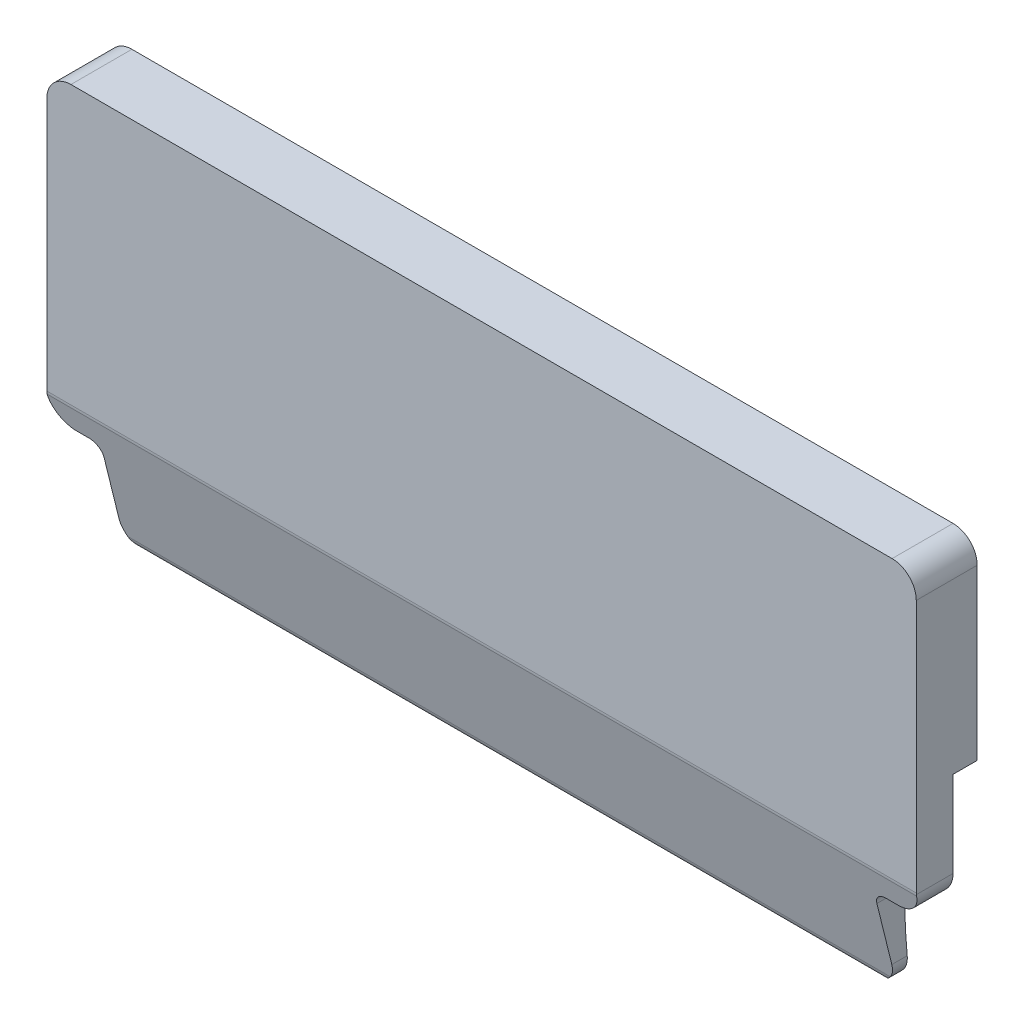
from build123d import *

# Parameters (mm, degrees)
BOSS_EXTRUDE1_DEPTH      = 1.5
BOSS_EXTRUDE1_DEPTH_BACK = 1.2
CUT_EXTRUDE1_DEPTH       = 40


with BuildPart() as part:
    # Sketch1 → Boss-Extrude1 (new body, two sides)
    with BuildSketch(Plane.XY) as boss_extrude1_sk:
        with BuildLine():
            Line((-17.999999991, 9.304537824), (-17.999999991, 10.304506021))
            Line((-17.999999991, 10.304506021), (-17.999999991, 17.303464443))
            ThreePointArc((-17.999999991, 17.303464443), (-17.707106772, 18.010571225), (-16.999999991, 18.303464443))
            Line((-16.999999991, 18.303464443), (16.999968161, 18.303464443))
            ThreePointArc((16.999968161, 18.303464443), (17.707074942, 18.010571225), (17.999968161, 17.303464443))
            Line((17.999968161, 17.303464443), (17.999968161, 9.303464443))
            Line((17.999968161, 9.303464443), (17.999968161, 6.751174458))
            ThreePointArc((17.999968161, 6.751174458), (17.707074942, 6.044067677), (16.999968161, 5.751174458))
            Line((16.999968161, 5.751174458), (16.499999991, 5.751174458))
            ThreePointArc((16.499999991, 5.751174458), (16.1464466, 5.604727849), (15.999999991, 5.251174458))
            Line((15.999999991, 5.251174458), (15.999999991, 2.751174458))
            ThreePointArc((15.999999991, 2.751174458), (15.707106772, 2.044067677), (14.999999991, 1.751174458))
            Line((14.999999991, 1.751174458), (-14.999999991, 1.751174458))
            ThreePointArc((-14.999999991, 1.751174458), (-15.707106772, 2.044067677), (-15.999999991, 2.751174458))
            Line((-15.999999991, 2.751174458), (-15.999999991, 5.251174458))
            ThreePointArc((-15.999999991, 5.251174458), (-16.1464466, 5.604727849), (-16.499999991, 5.751174458))
            Line((-16.499999991, 5.751174458), (-16.999999991, 5.751174458))
            ThreePointArc((-16.999999991, 5.751174458), (-17.707106772, 6.044067677), (-17.999999991, 6.751174458))
            Line((-17.999999991, 6.751174458), (-17.999999991, 9.304537824))
        make_face()
    extrude(amount=BOSS_EXTRUDE1_DEPTH)
    extrude(boss_extrude1_sk.sketch, amount=-BOSS_EXTRUDE1_DEPTH_BACK)

    # Sketch3 → Cut-Extrude1 (cut)
    with BuildSketch(Plane(origin=(17.999968161, 0, 0), x_dir=(0, 0, -1), z_dir=(1, 0, 0))):
        with BuildLine():
            Line((0.023796664, 6.751174458), (0.023796664, 5.754537824))
            ThreePointArc((0.023796664, 5.754537824), (0.053060483, 3.748723952), (0.23729316, 1.751174458))
            Line((0.23729316, 1.751174458), (1.2708887, 1.751174458))
            Line((1.2708887, 1.751174458), (1.2708887, 10.304537824))
            Line((1.2708887, 10.304537824), (1.2708887, 10.30507849))
            ThreePointArc((1.2708887, 10.30507849), (7.212872074, 16.614024598), (1.023796664, 22.680762846))
            Line((1.023796664, 22.680762846), (1.023796664, 17.303464443))
            Line((1.023796664, 17.303464443), (1.2, 17.303464443))
            Line((1.2, 17.303464443), (1.2, 6.751174458))
            Line((1.2, 6.751174458), (0.023796664, 6.751174458))
        make_face()
        Polygon((0.023796664, 10.304537824), (0.023796664, 6.751174458), (1.2, 6.751174458), (1.2, 17.303464443), (1.023796664, 17.303464443), (1.023796664, 10.304537824), align=None)
        with BuildLine():
            ThreePointArc((-1.485404738, 6.692099607), (-1.491731963, 6.721473521), (-1.496283327, 6.751174458))
            Line((-1.496283327, 6.751174458), (-1.5, 6.751174458))
            Line((-1.5, 6.751174458), (-1.5, 1.751174458))
            Line((-1.5, 1.751174458), (0.126821568, 1.751174458))
            ThreePointArc((0.126821568, 1.751174458), (-0.181429151, 1.857497567), (-0.358583171, 2.131248481))
            Line((-0.358583171, 2.131248481), (-1.485404738, 6.692099607))
        make_face()
        with BuildLine():
            Line((-1.5, 6.751174458), (-1.496283327, 6.751174458))
            ThreePointArc((-1.496283327, 6.751174458), (-1.499069967, 6.781543322), (-1.5, 6.812025585))
            Line((-1.5, 6.812025585), (-1.5, 6.751174458))
        make_face()
    extrude(amount=-CUT_EXTRUDE1_DEPTH, mode=Mode.SUBTRACT)


solid = part.part
